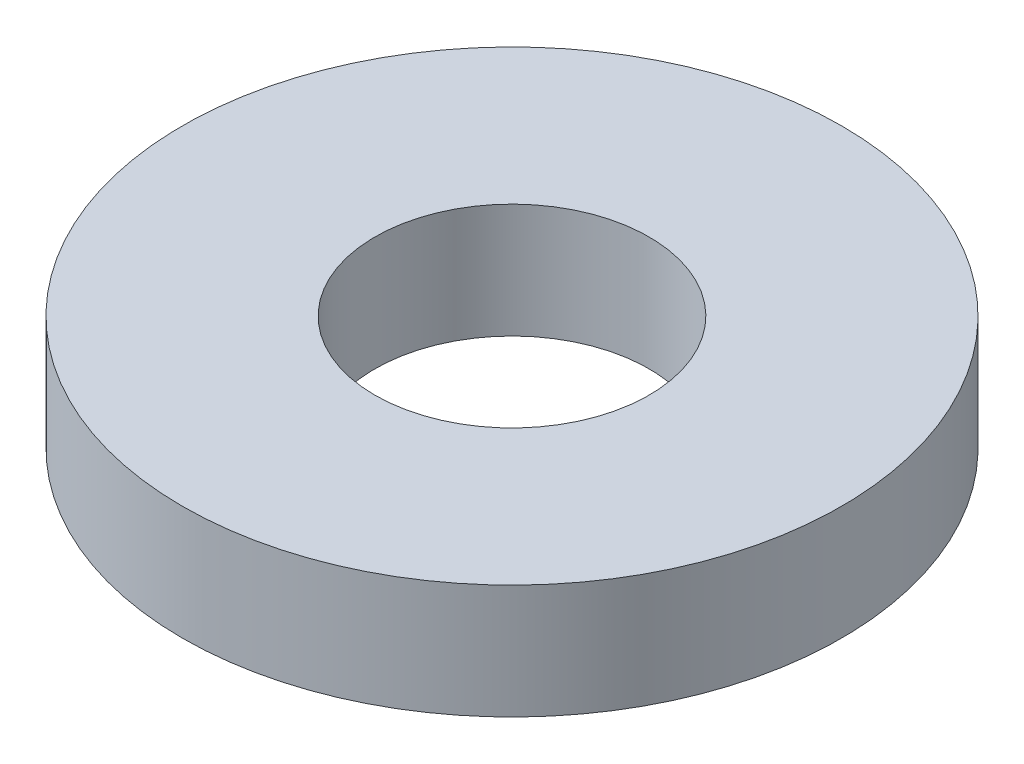
from build123d import *

# Parameters (mm, degrees)
SKETCH1_R           = 4.7625
BOSS_EXTRUDE1_DEPTH = 1.651
SKETCH5_R           = 1.9812
CUT_EXTRUDE1_DEPTH  = 2.651


with BuildPart() as part:
    # Sketch1 → Boss-Extrude1 (new body)
    with BuildSketch(Plane(origin=(0, 0, 0), x_dir=(1, 0, 0), z_dir=(0, 1, 0))):
        Circle(SKETCH1_R)
    extrude(amount=BOSS_EXTRUDE1_DEPTH)

    # Sketch5 → Cut-Extrude1 (cut, through all)
    with BuildSketch(Plane(origin=(0, 1.651, 0), x_dir=(-1, 0, 0), z_dir=(0, 1, 0))):
        Circle(SKETCH5_R)
    extrude(amount=-CUT_EXTRUDE1_DEPTH, mode=Mode.SUBTRACT)


solid = part.part
